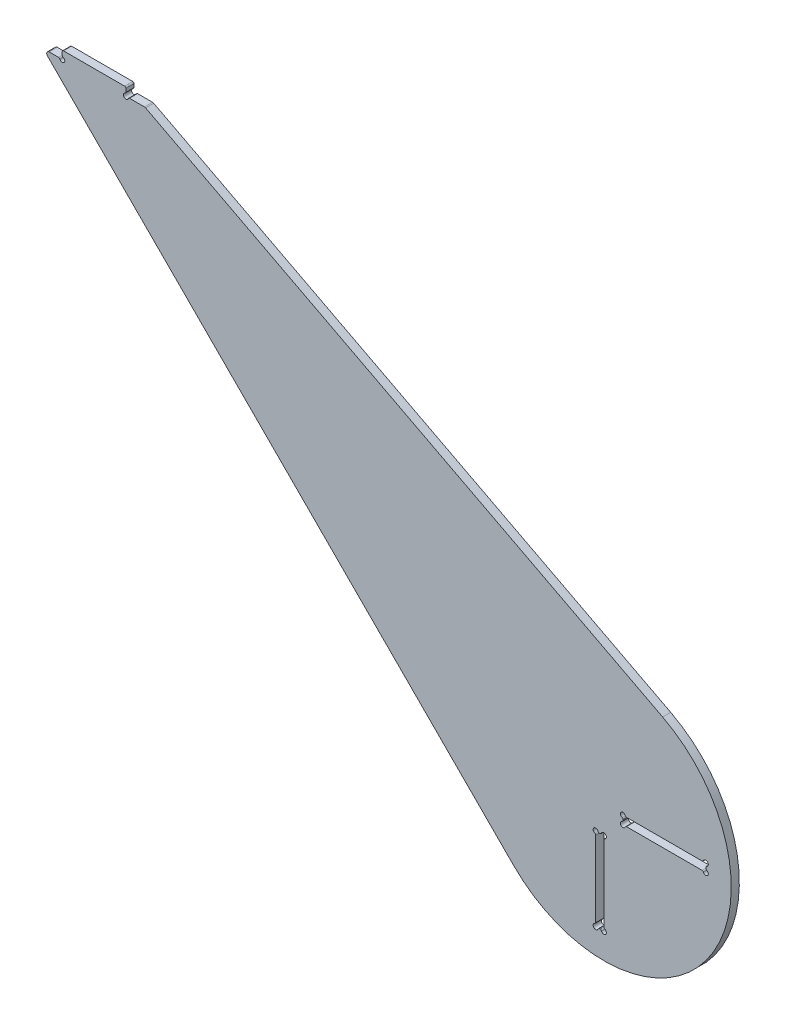
from build123d import *

# Parameters (mm, degrees)
SKETCH1_W           = 6.35
SKETCH1_H           = 65
SKETCH1_W_2         = 65
SKETCH1_H_2         = 6.35
BOSS_EXTRUDE1_DEPTH = 3.175
SKETCH2_W           = 50
SKETCH2_H           = 6.35
BOSS_EXTRUDE2_DEPTH = 6.35
SKETCH3_R           = 2
CUT_EXTRUDE1_DEPTH  = 7.35
FILLET1_R           = 1
SKETCH4_R           = 2
CUT_EXTRUDE2_DEPTH  = 7.35
FILLET2_R           = 1
FILLET3_R           = 2


with BuildPart() as part:
    # Sketch1 → Boss-Extrude1 (new body, symmetric)
    with BuildSketch(Plane.XY):
        with BuildLine():
            Line((-360, 300), (-440, 300))
            Line((-440, 300), (-70.846389974, -70.574705296))
            ThreePointArc((-70.846389974, -70.574705296), (80.595787705, -59.197288825), (46.150399684, 88.713812955))
            Line((46.150399684, 88.713812955), (-360, 300))
        make_face()
        with Locations((-3.175, -47.5)):
            Rectangle(SKETCH1_W, SKETCH1_H, mode=Mode.SUBTRACT)
        with Locations((47.5, 3.175)):
            Rectangle(SKETCH1_W_2, SKETCH1_H_2, mode=Mode.SUBTRACT)
    extrude(amount=BOSS_EXTRUDE1_DEPTH, both=True)

    # Sketch2 → Boss-Extrude2 (add)
    with BuildSketch(Plane.XY.offset(3.175)):
        with Locations((-400, 303.175)):
            Rectangle(SKETCH2_W, SKETCH2_H)
    extrude(amount=-BOSS_EXTRUDE2_DEPTH)

    # Sketch3 → Cut-Extrude1 (cut, through all)
    with BuildSketch(Plane.XY.offset(3.175)):
        with Locations((-6.35, -15)):
            Circle(SKETCH3_R)
        with Locations((0, -15)):
            Circle(SKETCH3_R)
        with Locations((-6.35, -80)):
            Circle(SKETCH3_R)
        with Locations((0, -80)):
            Circle(SKETCH3_R)
        with Locations((15, 0)):
            Circle(SKETCH3_R)
        with Locations((15, 6.35)):
            Circle(SKETCH3_R)
        with Locations((80, 6.35)):
            Circle(SKETCH3_R)
        with Locations((80, 0)):
            Circle(SKETCH3_R)
    extrude(amount=-CUT_EXTRUDE1_DEPTH, mode=Mode.SUBTRACT)

    # Fillet1
    fillet1_edges = [part.edges().sort_by_distance(p)[0] for p in [
        (17, 6.35, 0),
        (80, 4.35, 0),
        (78, 0, 0),
        (-6.35, -17, 0),
        (15, 4.35, 0),
        (15, 2, 0),
        (78, 6.35, 0),
        (80, 2, 0),
        (-4.35, -15, 0),
        (-2, -15, 0),
        (0, -78, 0),
        (-4.35, -80, 0),
        (17, 0, 0),
        (-2, -80, 0),
        (-6.35, -78, 0),
        (0, -17, 0),
    ]]
    fillet(fillet1_edges, radius=FILLET1_R)

    # Sketch4 → Cut-Extrude2 (cut, through all)
    with BuildSketch(Plane.XY.offset(3.175)):
        with Locations((-425, 300)):
            Circle(SKETCH4_R)
        with Locations((-375, 300)):
            Circle(SKETCH4_R)
    extrude(amount=-CUT_EXTRUDE2_DEPTH, mode=Mode.SUBTRACT)

    # Fillet2
    fillet2_edges = [part.edges().sort_by_distance(p)[0] for p in [
        (-375, 302, 0),
        (-425, 302, 0),
        (-427, 300, 0),
        (-373, 300, 0),
        (-425, 306.35, 0),
        (-375, 306.35, 0),
    ]]
    fillet(fillet2_edges, radius=FILLET2_R)

    # Fillet3
    fillet3_edges = [part.edges().sort_by_distance(p)[0] for p in [
        (-440, 300, 0),
        (-360, 300, 0),
    ]]
    fillet(fillet3_edges, radius=FILLET3_R)


solid = part.part
